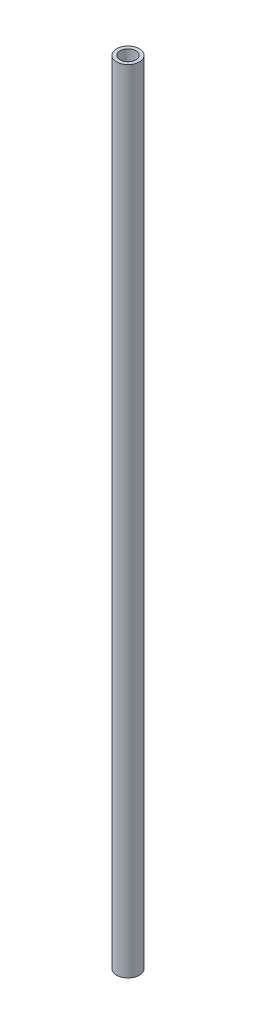
from build123d import *

# Parameters (mm, degrees)
SKETCH1_R           = 3.75
BOSS_EXTRUDE1_DEPTH = 260
SKETCH2_R           = 2.6
CUT_EXTRUDE2_DEPTH  = 261


with BuildPart() as part:
    # Sketch1 → Boss-Extrude1 (new body)
    with BuildSketch(Plane(origin=(0, 0, 0), x_dir=(1, 0, 0), z_dir=(0, 1, 0))):
        Circle(SKETCH1_R)
    extrude(amount=BOSS_EXTRUDE1_DEPTH)

    # Sketch2 → Cut-Extrude2 (cut, through all)
    with BuildSketch(Plane(origin=(0, 260, 0), x_dir=(1, 0, 0), z_dir=(0, 1, 0))):
        Circle(SKETCH2_R)
    extrude(amount=-CUT_EXTRUDE2_DEPTH, mode=Mode.SUBTRACT)


solid = part.part
